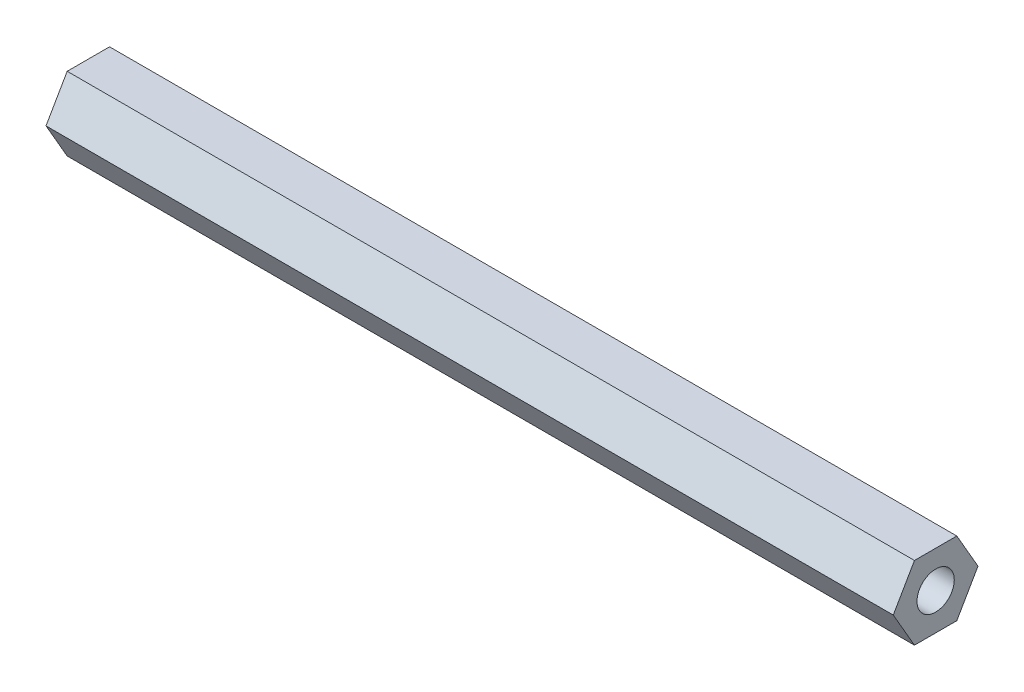
from build123d import *

# Parameters (mm, degrees)
SKETCH1_R           = 1.1
BOSS_EXTRUDE1_DEPTH = 50


with BuildPart() as part:
    # Sketch1 → Boss-Extrude1 (new body)
    with BuildSketch(Plane(origin=(0, 0, 0), x_dir=(0, 0, -1), z_dir=(1, 0, 0))):
        Polygon((1.25, 2.165063509), (-1.25, 2.165063509), (-2.5, 0), (-1.25, -2.165063509), (1.25, -2.165063509), (2.5, 0), align=None)
        Circle(SKETCH1_R, mode=Mode.SUBTRACT)
    extrude(amount=BOSS_EXTRUDE1_DEPTH)


solid = part.part
